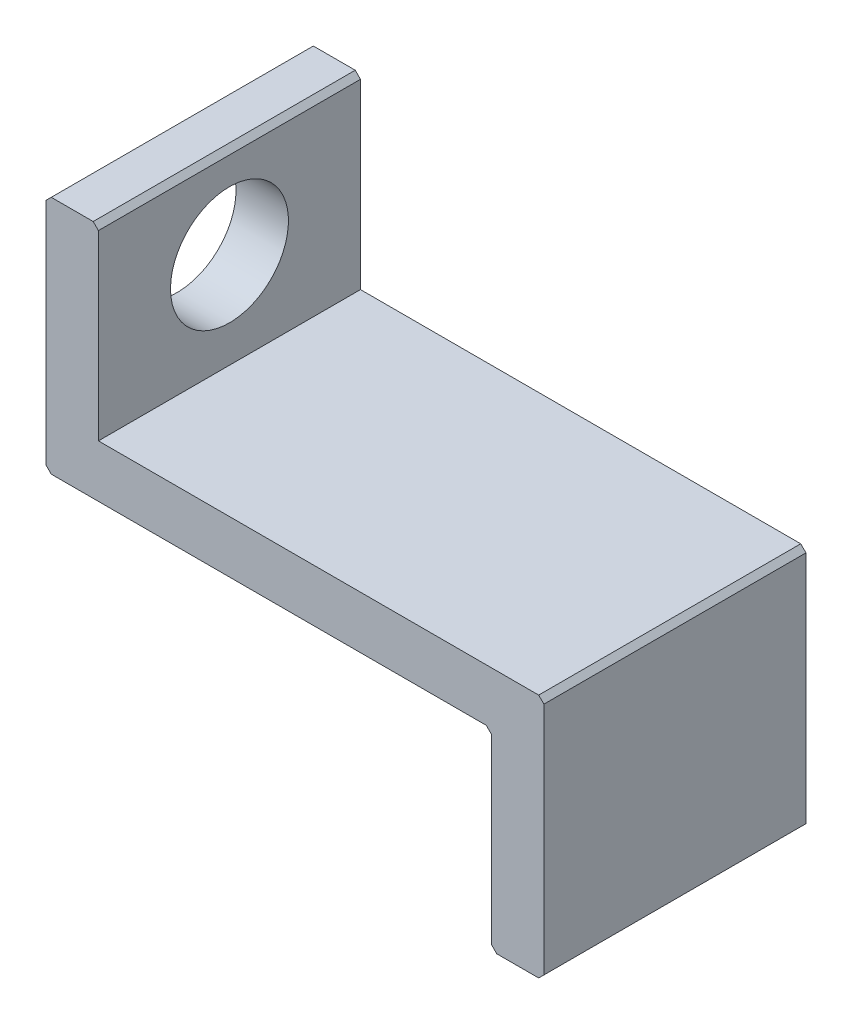
from build123d import *

# Parameters (mm, degrees)
BOSS_EXTRU_1_DEPTH = 10
CHANFREIN2_SIZE    = 0.2
D_GAGEMENT_M41_D   = 4.5


with BuildPart() as part:
    # Esquisse1 → Boss.-Extru.1 (new body)
    with BuildSketch(Plane.XY):
        Polygon((0, 32), (0, 41.35), (-17, 41.35), (-17, 48.5), (-19, 48.5), (-19, 39.35), (-2, 39.35), (-2, 32), align=None)
    extrude(amount=BOSS_EXTRU_1_DEPTH)

    # Chanfrein2
    chanfrein2_edges = [part.edges().sort_by_distance(p)[0] for p in [
        (0, 41.35, 5),
        (0, 32, 5),
        (-2, 32, 5),
        (-2, 39.35, 5),
        (-19, 39.35, 5),
        (-19, 48.5, 5),
        (-17, 48.5, 5),
    ]]
    chamfer(chanfrein2_edges, length=CHANFREIN2_SIZE)

    # Dégagement M41 (through all)
    with Locations(Plane.ZY.offset(19)):
        with Locations((5, 45)):
            Hole(D_GAGEMENT_M41_D / 2)


solid = part.part
